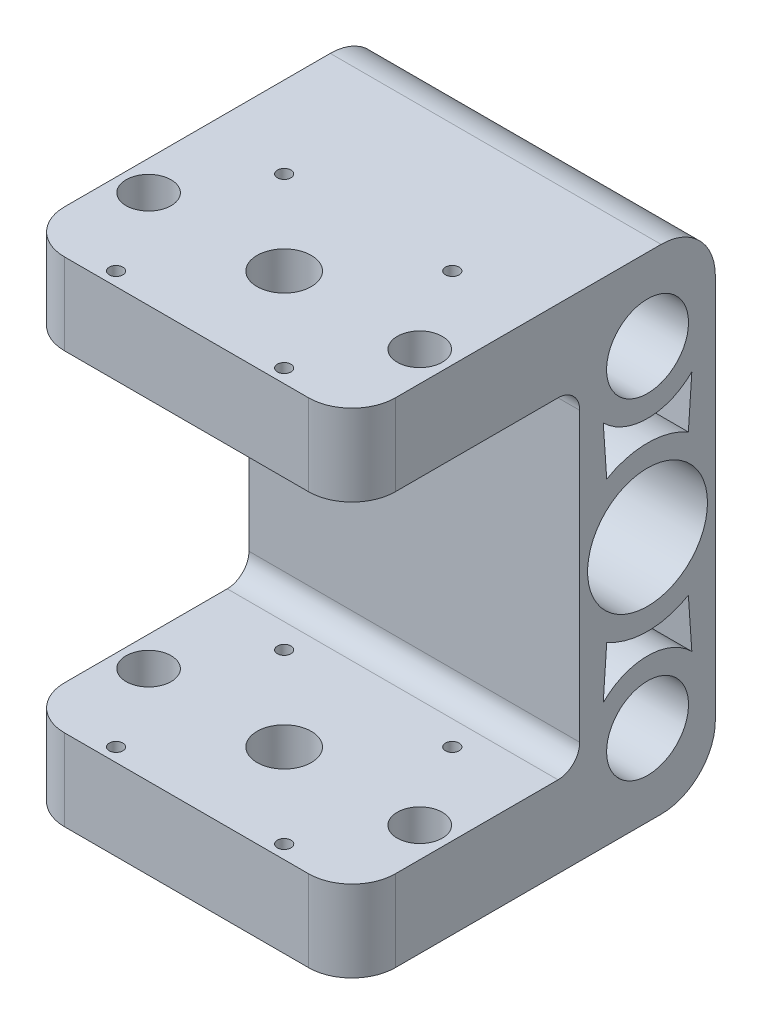
from build123d import *

# Parameters (mm, degrees)
SKETCH1_R                      = 5.05
SKETCH1_R_2                    = 7.55
BOSS_EXTRUDE1_DEPTH            = 30.5
CUT_EXTRUDE1_REACH             = 47.5
SKETCH2_R                      = 5
SKETCH2_R_2                    = 4.15
SKETCH2_R_3                    = 1.25
CUT_EXTRUDE1_DIRECTION_2_REACH = 47.5
CROQUIS4_W                     = 42
CROQUIS4_H                     = 61
CORTAR_EXTRUIR1_DEPTH          = 62
REDONDEO4_R                    = 4
REDONDEO5_R                    = 8
CROQUIS5_R                     = 11.05
CORTAR_EXTRUIR2_DEPTH          = 20
CROQUIS6_R                     = 1.25
CORTAR_EXTRUIR3_DEPTH          = 42
CORTAR_EXTRUIR4_DEPTH          = 61


with BuildPart() as part:
    # Sketch1 → Boss-Extrude1 (new body, symmetric)
    with BuildSketch(Plane(origin=(0, 0, 0), x_dir=(0, 0, -1), z_dir=(1, 0, 0))):
        with BuildLine():
            Line((0, 15.5), (0, -15.5))
            Line((0, -15.5), (-42, -15.5))
            Line((-42, -15.5), (-42, -45.5))
            Line((-42, -45.5), (15, -45.5))
            ThreePointArc((15, -45.5), (22.071067812, -42.571067812), (25, -35.5))
            Line((25, -35.5), (25, 35.5))
            ThreePointArc((25, 35.5), (22.071067812, 42.571067812), (15, 45.5))
            Line((15, 45.5), (-42, 45.5))
            Line((-42, 45.5), (-42, 15.5))
            Line((-42, 15.5), (0, 15.5))
        make_face()
        with Locations(Location((12.5, 0, 0), (0, 0, 180))):  # turned: the seam where the file's is
            Circle(SKETCH1_R, mode=Mode.SUBTRACT)
        with Locations((12.5, 30.5)):
            Circle(SKETCH1_R_2, mode=Mode.SUBTRACT)
        with Locations(Location((12.5, -30.5, 0), (0, 0, 180))):  # turned: the seam where the file's is
            Circle(SKETCH1_R_2, mode=Mode.SUBTRACT)
    extrude(amount=BOSS_EXTRUDE1_DEPTH, both=True)

    # Cut-Extrude1: up to this face of the body (flat: up to its plane)
    cut_extrude1_end = Plane(part.part.faces().sort_by_distance((0, 45.5, 13.5))[0])
    # Sketch2 → Cut-Extrude1 (cut, up to the picked face)
    with BuildSketch(Plane(origin=(0, 0, 0), x_dir=(1, 0, 0), z_dir=(0, 1, 0)), mode=Mode.PRIVATE) as cut_extrude1_sk1:
        with Locations(Location((0, -24, 0), (0, 0, 90))):  # turned: the seam where the file's is
            Circle(SKETCH2_R)
    cut_extrude1_tool1 = split(extrude(cut_extrude1_sk1.sketch, amount=CUT_EXTRUDE1_REACH, mode=Mode.PRIVATE), bisect_by=cut_extrude1_end, keep=Keep.BOTH, mode=Mode.PRIVATE)
    add(cut_extrude1_tool1.solids().sort_by(Axis((0, 0, 24), (0, 1, 0)))[0], mode=Mode.SUBTRACT)
    # Sketch2 → Cut-Extrude1 (cut, up to the picked face)
    with BuildSketch(Plane(origin=(0, 0, 0), x_dir=(1, 0, 0), z_dir=(0, 1, 0)), mode=Mode.PRIVATE) as cut_extrude1_sk2:
        with Locations(Location((25, -24, 0), (0, 0, 90))):  # turned: the seam where the file's is
            Circle(SKETCH2_R_2)
    cut_extrude1_tool2 = split(extrude(cut_extrude1_sk2.sketch, amount=CUT_EXTRUDE1_REACH, mode=Mode.PRIVATE), bisect_by=cut_extrude1_end, keep=Keep.BOTH, mode=Mode.PRIVATE)
    add(cut_extrude1_tool2.solids().sort_by(Axis((25, 0, 24), (0, 1, 0)))[0], mode=Mode.SUBTRACT)
    # Sketch2 → Cut-Extrude1 (cut, up to the picked face)
    with BuildSketch(Plane(origin=(0, 0, 0), x_dir=(1, 0, 0), z_dir=(0, 1, 0)), mode=Mode.PRIVATE) as cut_extrude1_sk3:
        with Locations(Location((-25, -24, 0), (0, 0, 90))):  # turned: the seam where the file's is
            Circle(SKETCH2_R_2)
    cut_extrude1_tool3 = split(extrude(cut_extrude1_sk3.sketch, amount=CUT_EXTRUDE1_REACH, mode=Mode.PRIVATE), bisect_by=cut_extrude1_end, keep=Keep.BOTH, mode=Mode.PRIVATE)
    add(cut_extrude1_tool3.solids().sort_by(Axis((-25, 0, 24), (0, 1, 0)))[0], mode=Mode.SUBTRACT)
    # Sketch2 → Cut-Extrude1 (cut, up to the picked face)
    with BuildSketch(Plane(origin=(0, 0, 0), x_dir=(1, 0, 0), z_dir=(0, 1, 0)), mode=Mode.PRIVATE) as cut_extrude1_sk4:
        with Locations(Location((15.5, -39.5, 0), (0, 0, 90))):  # turned: the seam where the file's is
            Circle(SKETCH2_R_3)
    cut_extrude1_tool4 = split(extrude(cut_extrude1_sk4.sketch, amount=CUT_EXTRUDE1_REACH, mode=Mode.PRIVATE), bisect_by=cut_extrude1_end, keep=Keep.BOTH, mode=Mode.PRIVATE)
    add(cut_extrude1_tool4.solids().sort_by(Axis((15.5, 0, 39.5), (0, 1, 0)))[0], mode=Mode.SUBTRACT)
    # Sketch2 → Cut-Extrude1 (cut, up to the picked face)
    with BuildSketch(Plane(origin=(0, 0, 0), x_dir=(1, 0, 0), z_dir=(0, 1, 0)), mode=Mode.PRIVATE) as cut_extrude1_sk5:
        with Locations(Location((-15.5, -39.5, 0), (0, 0, 90))):  # turned: the seam where the file's is
            Circle(SKETCH2_R_3)
    cut_extrude1_tool5 = split(extrude(cut_extrude1_sk5.sketch, amount=CUT_EXTRUDE1_REACH, mode=Mode.PRIVATE), bisect_by=cut_extrude1_end, keep=Keep.BOTH, mode=Mode.PRIVATE)
    add(cut_extrude1_tool5.solids().sort_by(Axis((-15.5, 0, 39.5), (0, 1, 0)))[0], mode=Mode.SUBTRACT)
    # Sketch2 → Cut-Extrude1 (cut, up to the picked face)
    with BuildSketch(Plane(origin=(0, 0, 0), x_dir=(1, 0, 0), z_dir=(0, 1, 0)), mode=Mode.PRIVATE) as cut_extrude1_sk6:
        with Locations(Location((-15.5, -8.5, 0), (0, 0, 90))):  # turned: the seam where the file's is
            Circle(SKETCH2_R_3)
    cut_extrude1_tool6 = split(extrude(cut_extrude1_sk6.sketch, amount=CUT_EXTRUDE1_REACH, mode=Mode.PRIVATE), bisect_by=cut_extrude1_end, keep=Keep.BOTH, mode=Mode.PRIVATE)
    add(cut_extrude1_tool6.solids().sort_by(Axis((-15.5, 0, 8.5), (0, 1, 0)))[0], mode=Mode.SUBTRACT)
    # Sketch2 → Cut-Extrude1 (cut, up to the picked face)
    with BuildSketch(Plane(origin=(0, 0, 0), x_dir=(1, 0, 0), z_dir=(0, 1, 0)), mode=Mode.PRIVATE) as cut_extrude1_sk7:
        with Locations(Location((15.5, -8.5, 0), (0, 0, 90))):  # turned: the seam where the file's is
            Circle(SKETCH2_R_3)
    cut_extrude1_tool7 = split(extrude(cut_extrude1_sk7.sketch, amount=CUT_EXTRUDE1_REACH, mode=Mode.PRIVATE), bisect_by=cut_extrude1_end, keep=Keep.BOTH, mode=Mode.PRIVATE)
    add(cut_extrude1_tool7.solids().sort_by(Axis((15.5, 0, 8.5), (0, 1, 0)))[0], mode=Mode.SUBTRACT)

    # Cut-Extrude1 direction 2: up to this face of the body (flat: up to its plane)
    cut_extrude1_direction_2_end = Plane(part.part.faces().sort_by_distance((0, -45.5, 13.5))[0])
    # Sketch2 → Cut-Extrude1 direction 2 (cut, up to the picked face)
    with BuildSketch(Plane(origin=(0, 0, 0), x_dir=(1, 0, 0), z_dir=(0, 1, 0)), mode=Mode.PRIVATE) as cut_extrude1_direction_2_sk1:
        with Locations(Location((0, -24, 0), (0, 0, 90))):  # turned: the seam where the file's is
            Circle(SKETCH2_R)
    cut_extrude1_direction_2_tool1 = split(extrude(cut_extrude1_direction_2_sk1.sketch, amount=-CUT_EXTRUDE1_DIRECTION_2_REACH, mode=Mode.PRIVATE), bisect_by=cut_extrude1_direction_2_end, keep=Keep.BOTH, mode=Mode.PRIVATE)
    add(cut_extrude1_direction_2_tool1.solids().sort_by(Axis((0, 0, 24), (0, -1, 0)))[0], mode=Mode.SUBTRACT)
    # Sketch2 → Cut-Extrude1 direction 2 (cut, up to the picked face)
    with BuildSketch(Plane(origin=(0, 0, 0), x_dir=(1, 0, 0), z_dir=(0, 1, 0)), mode=Mode.PRIVATE) as cut_extrude1_direction_2_sk2:
        with Locations(Location((25, -24, 0), (0, 0, 90))):  # turned: the seam where the file's is
            Circle(SKETCH2_R_2)
    cut_extrude1_direction_2_tool2 = split(extrude(cut_extrude1_direction_2_sk2.sketch, amount=-CUT_EXTRUDE1_DIRECTION_2_REACH, mode=Mode.PRIVATE), bisect_by=cut_extrude1_direction_2_end, keep=Keep.BOTH, mode=Mode.PRIVATE)
    add(cut_extrude1_direction_2_tool2.solids().sort_by(Axis((25, 0, 24), (0, -1, 0)))[0], mode=Mode.SUBTRACT)
    # Sketch2 → Cut-Extrude1 direction 2 (cut, up to the picked face)
    with BuildSketch(Plane(origin=(0, 0, 0), x_dir=(1, 0, 0), z_dir=(0, 1, 0)), mode=Mode.PRIVATE) as cut_extrude1_direction_2_sk3:
        with Locations(Location((-25, -24, 0), (0, 0, 90))):  # turned: the seam where the file's is
            Circle(SKETCH2_R_2)
    cut_extrude1_direction_2_tool3 = split(extrude(cut_extrude1_direction_2_sk3.sketch, amount=-CUT_EXTRUDE1_DIRECTION_2_REACH, mode=Mode.PRIVATE), bisect_by=cut_extrude1_direction_2_end, keep=Keep.BOTH, mode=Mode.PRIVATE)
    add(cut_extrude1_direction_2_tool3.solids().sort_by(Axis((-25, 0, 24), (0, -1, 0)))[0], mode=Mode.SUBTRACT)
    # Sketch2 → Cut-Extrude1 direction 2 (cut, up to the picked face)
    with BuildSketch(Plane(origin=(0, 0, 0), x_dir=(1, 0, 0), z_dir=(0, 1, 0)), mode=Mode.PRIVATE) as cut_extrude1_direction_2_sk4:
        with Locations(Location((15.5, -39.5, 0), (0, 0, 90))):  # turned: the seam where the file's is
            Circle(SKETCH2_R_3)
    cut_extrude1_direction_2_tool4 = split(extrude(cut_extrude1_direction_2_sk4.sketch, amount=-CUT_EXTRUDE1_DIRECTION_2_REACH, mode=Mode.PRIVATE), bisect_by=cut_extrude1_direction_2_end, keep=Keep.BOTH, mode=Mode.PRIVATE)
    add(cut_extrude1_direction_2_tool4.solids().sort_by(Axis((15.5, 0, 39.5), (0, -1, 0)))[0], mode=Mode.SUBTRACT)
    # Sketch2 → Cut-Extrude1 direction 2 (cut, up to the picked face)
    with BuildSketch(Plane(origin=(0, 0, 0), x_dir=(1, 0, 0), z_dir=(0, 1, 0)), mode=Mode.PRIVATE) as cut_extrude1_direction_2_sk5:
        with Locations(Location((-15.5, -39.5, 0), (0, 0, 90))):  # turned: the seam where the file's is
            Circle(SKETCH2_R_3)
    cut_extrude1_direction_2_tool5 = split(extrude(cut_extrude1_direction_2_sk5.sketch, amount=-CUT_EXTRUDE1_DIRECTION_2_REACH, mode=Mode.PRIVATE), bisect_by=cut_extrude1_direction_2_end, keep=Keep.BOTH, mode=Mode.PRIVATE)
    add(cut_extrude1_direction_2_tool5.solids().sort_by(Axis((-15.5, 0, 39.5), (0, -1, 0)))[0], mode=Mode.SUBTRACT)
    # Sketch2 → Cut-Extrude1 direction 2 (cut, up to the picked face)
    with BuildSketch(Plane(origin=(0, 0, 0), x_dir=(1, 0, 0), z_dir=(0, 1, 0)), mode=Mode.PRIVATE) as cut_extrude1_direction_2_sk6:
        with Locations(Location((-15.5, -8.5, 0), (0, 0, 90))):  # turned: the seam where the file's is
            Circle(SKETCH2_R_3)
    cut_extrude1_direction_2_tool6 = split(extrude(cut_extrude1_direction_2_sk6.sketch, amount=-CUT_EXTRUDE1_DIRECTION_2_REACH, mode=Mode.PRIVATE), bisect_by=cut_extrude1_direction_2_end, keep=Keep.BOTH, mode=Mode.PRIVATE)
    add(cut_extrude1_direction_2_tool6.solids().sort_by(Axis((-15.5, 0, 8.5), (0, -1, 0)))[0], mode=Mode.SUBTRACT)
    # Sketch2 → Cut-Extrude1 direction 2 (cut, up to the picked face)
    with BuildSketch(Plane(origin=(0, 0, 0), x_dir=(1, 0, 0), z_dir=(0, 1, 0)), mode=Mode.PRIVATE) as cut_extrude1_direction_2_sk7:
        with Locations(Location((15.5, -8.5, 0), (0, 0, 90))):  # turned: the seam where the file's is
            Circle(SKETCH2_R_3)
    cut_extrude1_direction_2_tool7 = split(extrude(cut_extrude1_direction_2_sk7.sketch, amount=-CUT_EXTRUDE1_DIRECTION_2_REACH, mode=Mode.PRIVATE), bisect_by=cut_extrude1_direction_2_end, keep=Keep.BOTH, mode=Mode.PRIVATE)
    add(cut_extrude1_direction_2_tool7.solids().sort_by(Axis((15.5, 0, 8.5), (0, -1, 0)))[0], mode=Mode.SUBTRACT)

    # Croquis4 → Cortar-Extruir1 (cut, through all)
    with BuildSketch(Plane(origin=(30.5, 0, 0), x_dir=(0, 0, -1), z_dir=(1, 0, 0))):
        with Locations((-21, 0)):
            Rectangle(CROQUIS4_W, CROQUIS4_H)
    extrude(amount=-CORTAR_EXTRUIR1_DEPTH, mode=Mode.SUBTRACT)

    # Redondeo4
    redondeo4_edges = [part.edges().sort_by_distance(p)[0] for p in [
        (0, 30.5, 0),
        (0, -30.5, 0),
    ]]
    fillet(redondeo4_edges, radius=REDONDEO4_R)

    # Redondeo5
    redondeo5_edges = [part.edges().sort_by_distance(p)[0] for p in [
        (-30.5, 38, 42),
        (-30.5, -38, 42),
        (30.5, -38, 42),
        (30.5, 38, 42),
    ]]
    fillet(redondeo5_edges, radius=REDONDEO5_R)

    # Croquis5 → Cortar-Extruir2 (cut)
    with BuildSketch(Plane(origin=(30.5, 0, 0), x_dir=(0, 0, -1), z_dir=(1, 0, 0))):
        with Locations((12.5, 0)):
            Circle(CROQUIS5_R)
    extrude(amount=-CORTAR_EXTRUIR2_DEPTH, mode=Mode.SUBTRACT)

    # Croquis6 → Cortar-Extruir3 (cut, through all)
    with BuildSketch(Plane(origin=(10.5, 0, 0), x_dir=(0, 0, -1), z_dir=(1, 0, 0))):
        with Locations((12.5, 8)):
            Circle(CROQUIS6_R)
        with Locations((20.5, 0)):
            Circle(CROQUIS6_R)
        with Locations((12.5, -8)):
            Circle(CROQUIS6_R)
        with Locations((4.5, 0)):
            Circle(CROQUIS6_R)
    extrude(amount=-CORTAR_EXTRUIR3_DEPTH, mode=Mode.SUBTRACT)

    # Croquis8 → Cortar-Extruir4 (cut)
    with BuildSketch(Plane(origin=(30.5, 0, 0), x_dir=(0, 0, -1), z_dir=(1, 0, 0))):
        with BuildLine():
            Line((4.332916677, 22.332916677), (4.975, 13.033682327))
            ThreePointArc((4.975, 13.033682327), (12.5, 15.05), (20.025, 13.033682327))
            Line((20.025, 13.033682327), (20.667083323, 22.332916677))
            ThreePointArc((20.667083323, 22.332916677), (12.5, 18.95), (4.332916677, 22.332916677))
        make_face()
        with BuildLine():
            Line((4.332916677, -22.332916677), (4.975, -13.033682327))
            ThreePointArc((4.975, -13.033682327), (12.5, -15.05), (20.025, -13.033682327))
            Line((20.025, -13.033682327), (20.667083323, -22.332916677))
            ThreePointArc((20.667083323, -22.332916677), (12.5, -18.95), (4.332916677, -22.332916677))
        make_face()
    extrude(amount=-CORTAR_EXTRUIR4_DEPTH, mode=Mode.SUBTRACT)


solid = part.part
